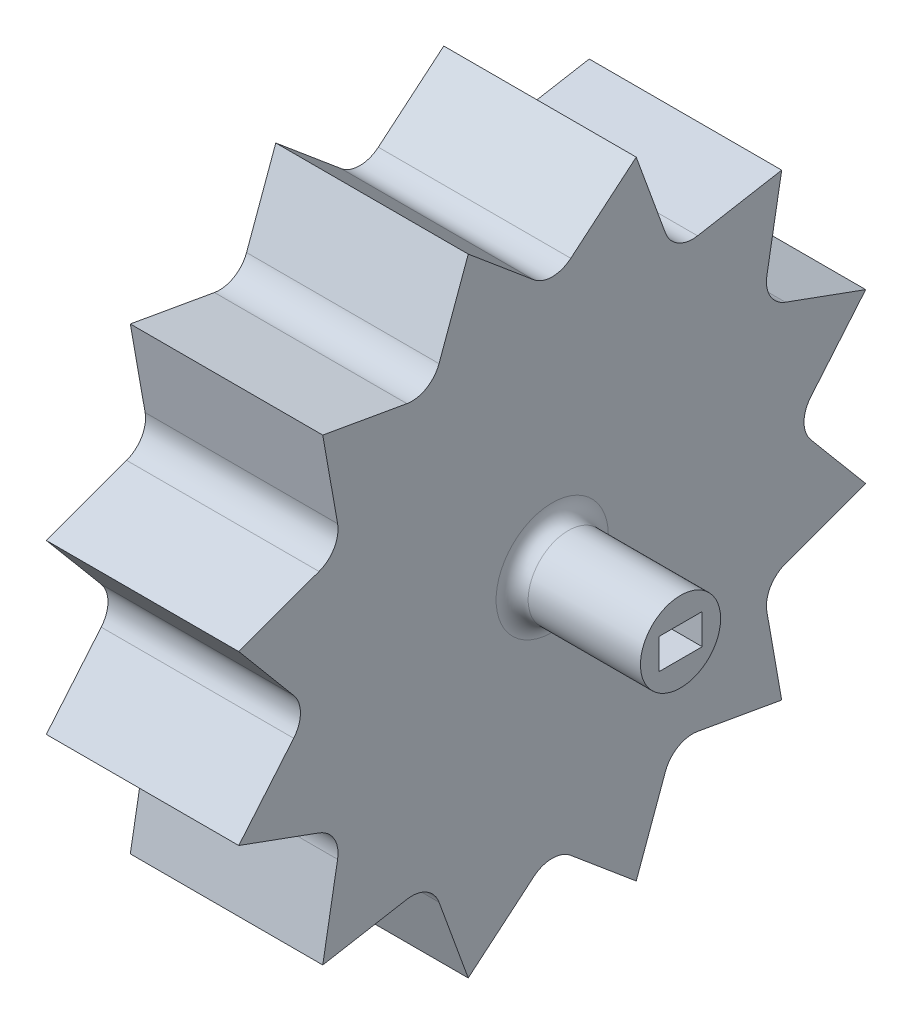
from build123d import *

# Parameters (mm, degrees)
BOSS_EXTRUDE1_DEPTH = 24
SKETCH2_R           = 5
BOSS_EXTRUDE2_DEPTH = 16
FILLET1_R           = 2
SKETCH4_W           = 5.41
SKETCH4_H           = 3.8
CUT_EXTRUDE1_DEPTH  = 20


with BuildPart() as part:
    # Sketch1 → Boss-Extrude1 (new body)
    with BuildSketch(Plane(origin=(0, 0, 0), x_dir=(0, 0, -1), z_dir=(1, 0, 0))):
        with BuildLine():
            Line((2.314035395, 32.242240005), (10.473918124, 39.089194593))
            Line((10.473918124, 39.089194593), (14.117106565, 29.079616616))
            ThreePointArc((14.117106565, 29.079616616), (15.7, 27.193197679), (18.12513344, 26.765581222))
            Line((18.12513344, 26.765581222), (28.615276469, 28.615276469))
            Line((28.615276469, 28.615276469), (26.765581222, 18.12513344))
            ThreePointArc((26.765581222, 18.12513344), (27.193197679, 15.7), (29.079616616, 14.117106565))
            Line((29.079616616, 14.117106565), (39.089194593, 10.473918124))
            Line((39.089194593, 10.473918124), (32.242240005, 2.314035395))
            ThreePointArc((32.242240005, 2.314035395), (31.4, 0), (32.242240005, -2.314035395))
            Line((32.242240005, -2.314035395), (39.089194593, -10.473918124))
            Line((39.089194593, -10.473918124), (29.079616616, -14.117106565))
            ThreePointArc((29.079616616, -14.117106565), (27.193197679, -15.7), (26.765581222, -18.12513344))
            Line((26.765581222, -18.12513344), (28.615276469, -28.615276469))
            Line((28.615276469, -28.615276469), (18.12513344, -26.765581222))
            ThreePointArc((18.12513344, -26.765581222), (15.7, -27.193197679), (14.117106565, -29.079616616))
            Line((14.117106565, -29.079616616), (10.473918124, -39.089194593))
            Line((10.473918124, -39.089194593), (2.314035395, -32.242240005))
            ThreePointArc((2.314035395, -32.242240005), (0, -31.4), (-2.314035395, -32.242240005))
            Line((-2.314035395, -32.242240005), (-10.473918124, -39.089194593))
            Line((-10.473918124, -39.089194593), (-14.117106565, -29.079616616))
            ThreePointArc((-14.117106565, -29.079616616), (-15.7, -27.193197679), (-18.12513344, -26.765581222))
            Line((-18.12513344, -26.765581222), (-28.615276469, -28.615276469))
            Line((-28.615276469, -28.615276469), (-26.765581222, -18.12513344))
            ThreePointArc((-26.765581222, -18.12513344), (-27.193197679, -15.7), (-29.079616616, -14.117106565))
            Line((-29.079616616, -14.117106565), (-39.089194593, -10.473918124))
            Line((-39.089194593, -10.473918124), (-32.242240005, -2.314035395))
            ThreePointArc((-32.242240005, -2.314035395), (-31.4, 0), (-32.242240005, 2.314035395))
            Line((-32.242240005, 2.314035395), (-39.089194593, 10.473918124))
            Line((-39.089194593, 10.473918124), (-29.079616616, 14.117106565))
            ThreePointArc((-29.079616616, 14.117106565), (-27.193197679, 15.7), (-26.765581222, 18.12513344))
            Line((-26.765581222, 18.12513344), (-28.615276469, 28.615276469))
            Line((-28.615276469, 28.615276469), (-18.12513344, 26.765581222))
            ThreePointArc((-18.12513344, 26.765581222), (-15.7, 27.193197679), (-14.117106565, 29.079616616))
            Line((-14.117106565, 29.079616616), (-10.473918124, 39.089194593))
            Line((-10.473918124, 39.089194593), (-2.314035395, 32.242240005))
            ThreePointArc((-2.314035395, 32.242240005), (0, 31.4), (2.314035395, 32.242240005))
        make_face()
    extrude(amount=BOSS_EXTRUDE1_DEPTH)

    # Sketch2 → Boss-Extrude2 (add)
    with BuildSketch(Plane(origin=(24, 0, 0), x_dir=(0, 0, -1), z_dir=(1, 0, 0))):
        Circle(SKETCH2_R)
    extrude(amount=BOSS_EXTRUDE2_DEPTH)

    # Fillet1
    fillet1_edges = [part.edges().sort_by_distance(p)[0] for p in [
        (24, 0, 5),
    ]]
    fillet(fillet1_edges, radius=FILLET1_R)

    # Sketch4 → Cut-Extrude1 (cut)
    with BuildSketch(Plane(origin=(40, 0, 0), x_dir=(0, 0, -1), z_dir=(1, 0, 0))):
        Rectangle(SKETCH4_W, SKETCH4_H)
    extrude(amount=-CUT_EXTRUDE1_DEPTH, mode=Mode.SUBTRACT)


solid = part.part
